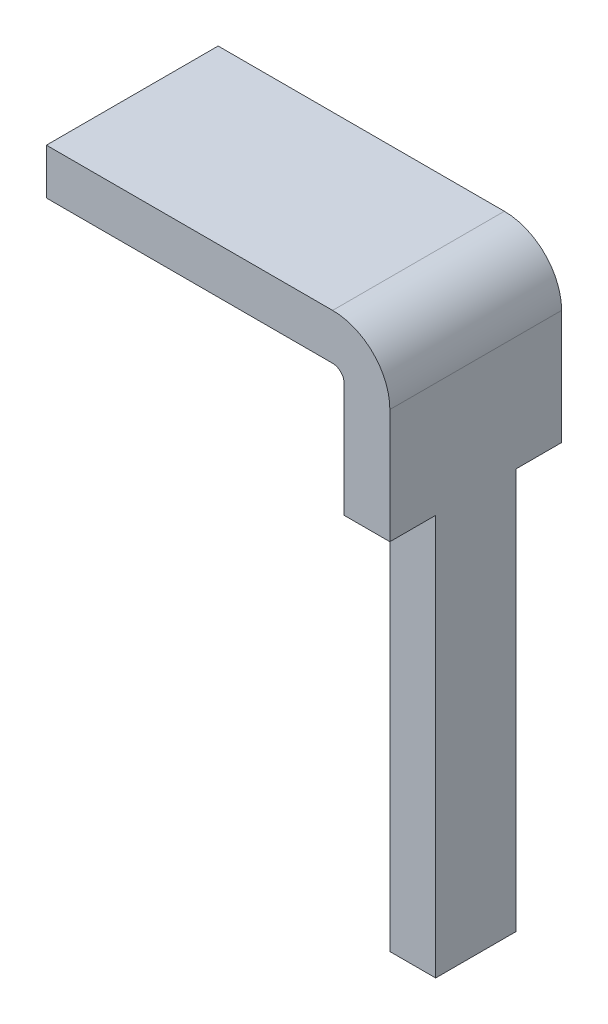
from build123d import *

# Parameters (mm, degrees)
BOSS_EXTRUDE1_DEPTH = 1.5
SKETCH2_W           = 0.4
SKETCH2_H           = 3.5
CUT_EXTRUDE1_DEPTH  = 1.5


with BuildPart() as part:
    # Sketch1 → Boss-Extrude1 (new body)
    with BuildSketch(Plane.XY):
        with BuildLine():
            Line((0, 0), (2.5, 0))
            ThreePointArc((2.5, 0), (2.853553391, -0.146446609), (3, -0.5))
            Line((3, -0.5), (3, -5))
            Line((3, -5), (2.6, -5))
            Line((2.6, -5), (2.6, -0.5))
            ThreePointArc((2.6, -0.5), (2.570710678, -0.429289322), (2.5, -0.4))
            Line((2.5, -0.4), (0, -0.4))
            Line((0, -0.4), (0, 0))
        make_face()
    extrude(amount=BOSS_EXTRUDE1_DEPTH)

    # Sketch2 → Cut-Extrude1 (cut)
    with BuildSketch(Plane(origin=(3, 0, 0), x_dir=(0, 0, -1), z_dir=(1, 0, 0))):
        with Locations((-1.3, -3.25)):
            Rectangle(SKETCH2_W, SKETCH2_H)
        with Locations((-0.2, -3.25)):
            Rectangle(SKETCH2_W, SKETCH2_H)
    extrude(amount=-CUT_EXTRUDE1_DEPTH, mode=Mode.SUBTRACT)


solid = part.part
